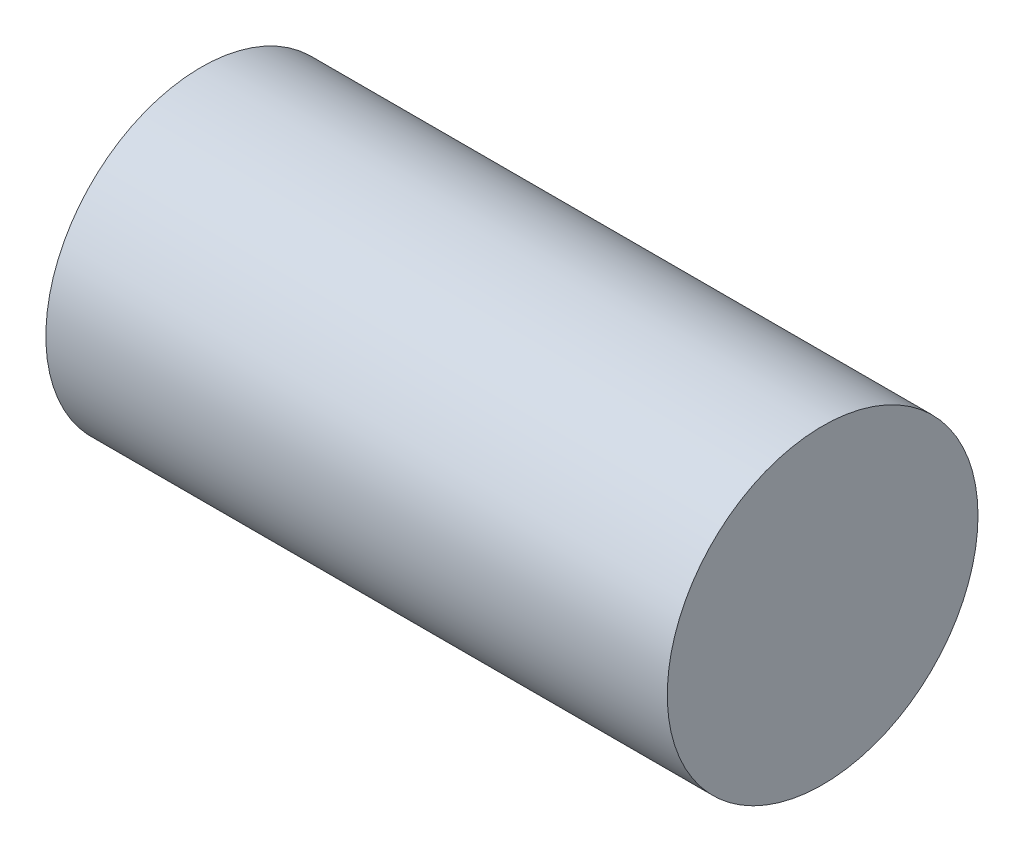
from build123d import *

# Parameters (mm, degrees)
SKETCH1_R      = 2.5
EXTRUDE1_DEPTH = 10


with BuildPart() as part:
    # Sketch1 → Extrude1 (new body)
    with BuildSketch(Plane(origin=(0, 0, 0), x_dir=(0, 0, -1), z_dir=(1, 0, 0))):
        Circle(SKETCH1_R)
    extrude(amount=EXTRUDE1_DEPTH)


solid = part.part
